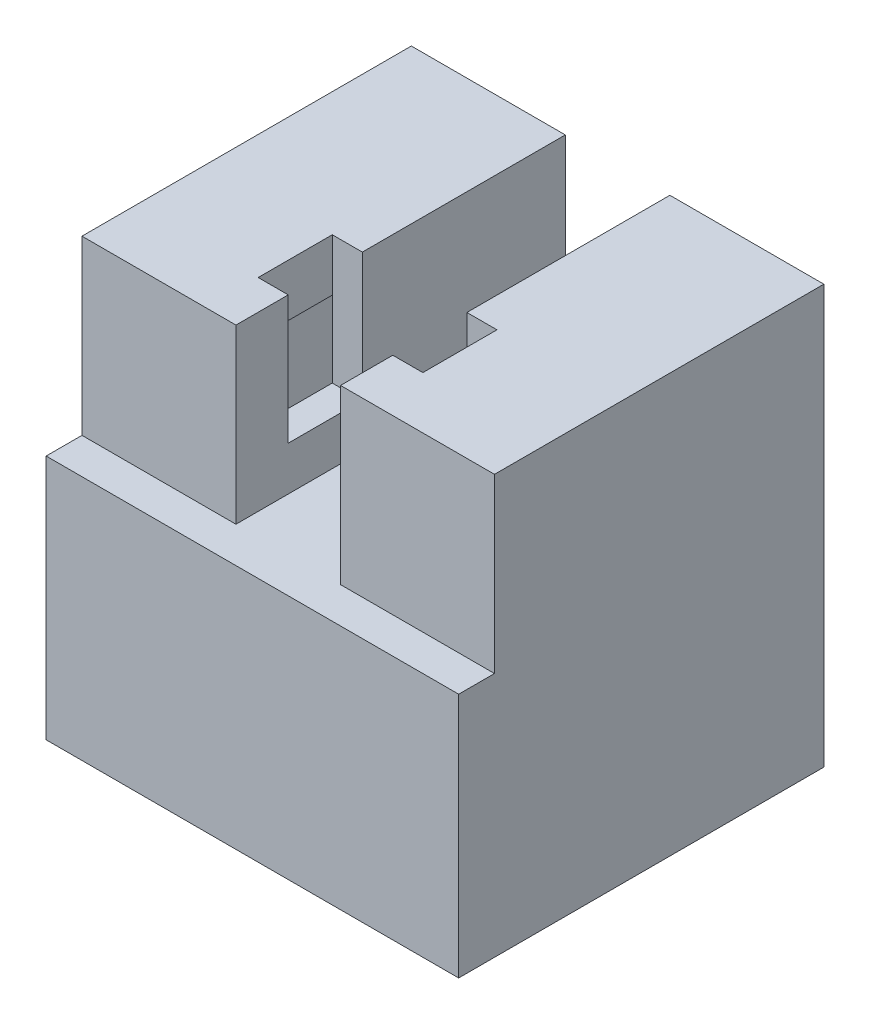
from build123d import *

# Parameters (mm, degrees)
SKETCH2_W           = 18.7
SKETCH2_H           = 20
BOSS_EXTRUDE1_DEPTH = 25.4
SKETCH3_W           = 6.35
SKETCH3_H           = 7.3
SKETCH3_H_2         = 3.175
CUT_EXTRUDE1_DEPTH  = 21
SKETCH5_W           = 3.175
SKETCH5_H           = 25.4
BOSS_EXTRUDE2_DEPTH = 20
SKETCH6_W           = 10
SKETCH6_H           = 10.125
CUT_EXTRUDE2_DEPTH  = 16.825
SKETCH7_W           = 3
SKETCH7_H           = 3.5
CUT_EXTRUDE3_DEPTH  = 10
SKETCH8_W           = 22
SKETCH8_H           = 10.125
CUT_EXTRUDE4_DEPTH  = 19
SKETCH9_W           = 2.175
SKETCH9_H           = 14.925
BOSS_EXTRUDE3_DEPTH = 25.05
SKETCH10_W          = 1.825
SKETCH10_H          = 7.8
CUT_EXTRUDE5_DEPTH  = 4.5


with BuildPart() as part:
    # Sketch2 → Boss-Extrude1 (new body)
    with BuildSketch(Plane(origin=(0, 0, 0), x_dir=(1, 0, 0), z_dir=(0, 1, 0))):
        Rectangle(SKETCH2_W, SKETCH2_H)
    extrude(amount=BOSS_EXTRUDE1_DEPTH)

    # Sketch3 → Cut-Extrude1 (cut, through all)
    with BuildSketch(Plane(origin=(0, 0, -10), x_dir=(-1, 0, 0), z_dir=(0, 0, -1))):
        with Locations((0, 21.75)):
            Rectangle(SKETCH3_W, SKETCH3_H)
        with Locations((0, 16.5125)):
            Rectangle(SKETCH3_W, SKETCH3_H_2)
    extrude(amount=-CUT_EXTRUDE1_DEPTH, mode=Mode.SUBTRACT)

    # Sketch5 → Boss-Extrude2 (add)
    with BuildSketch(Plane(origin=(0, 0, -10), x_dir=(-1, 0, 0), z_dir=(0, 0, -1))):
        with Locations((-10.9375, 12.7)):
            Rectangle(SKETCH5_W, SKETCH5_H)
        with Locations((10.9375, 12.7)):
            Rectangle(SKETCH5_W, SKETCH5_H)
    extrude(amount=-BOSS_EXTRUDE2_DEPTH)

    # Sketch6 → Cut-Extrude2 (cut)
    with BuildSketch(Plane(origin=(0, 0, -10), x_dir=(-1, 0, 0), z_dir=(0, 0, -1))):
        Polygon((5, 22.225), (5, 10.125), (5, 0), (9.35, 0), (9.35, 22.225), align=None)
        with Locations((0, 5.0625)):
            Rectangle(SKETCH6_W, SKETCH6_H)
        Polygon((-5, 22.225), (-9.35, 22.225), (-9.35, 0), (-5, 0), (-5, 10.125), align=None)
    extrude(amount=-CUT_EXTRUDE2_DEPTH, mode=Mode.SUBTRACT)

    # Sketch7 → Cut-Extrude3 (cut)
    with BuildSketch(Plane(origin=(5, 0, 0), x_dir=(0, 0, -1), z_dir=(1, 0, 0))):
        with Locations((-4.825, 19.725)):
            Rectangle(SKETCH7_W, SKETCH7_H)
    extrude(amount=-CUT_EXTRUDE3_DEPTH, mode=Mode.SUBTRACT)

    # Sketch8 → Cut-Extrude4 (cut)
    with BuildSketch(Plane(origin=(0, 0, -10), x_dir=(-1, 0, 0), z_dir=(0, 0, -1))):
        with Locations((0, 5.0625)):
            Rectangle(SKETCH8_W, SKETCH8_H)
    extrude(amount=-CUT_EXTRUDE4_DEPTH, mode=Mode.SUBTRACT)

    # Sketch9 → Boss-Extrude3 (add)
    with BuildSketch(Plane(origin=(12.525, 0, 0), x_dir=(0, 0, -1), z_dir=(1, 0, 0))):
        with Locations((-11.0875, 7.4625)):
            Rectangle(SKETCH9_W, SKETCH9_H)
    extrude(amount=-BOSS_EXTRUDE3_DEPTH)

    # Sketch10 → Cut-Extrude5 (cut)
    with BuildSketch(Plane(origin=(0, 0, 2.325), x_dir=(-1, 0, 0), z_dir=(0, 0, -1))):
        with Locations((-4.0875, 21.5)):
            Rectangle(SKETCH10_W, SKETCH10_H)
        with Locations((4.0875, 21.5)):
            Rectangle(SKETCH10_W, SKETCH10_H)
    extrude(amount=-CUT_EXTRUDE5_DEPTH, mode=Mode.SUBTRACT)


solid = part.part
